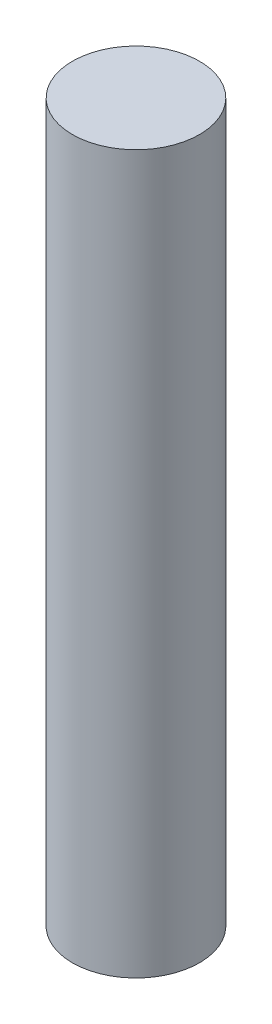
from build123d import *

# Parameters (mm, degrees)
CROQUIS1_R              = 22.5
SALIENTE_EXTRUIR1_DEPTH = 254


with BuildPart() as part:
    # Croquis1 → Saliente-Extruir1 (new body)
    with BuildSketch(Plane(origin=(0, 0, 0), x_dir=(1, 0, 0), z_dir=(0, 1, 0))):
        Circle(CROQUIS1_R)
    extrude(amount=SALIENTE_EXTRUIR1_DEPTH)


solid = part.part
